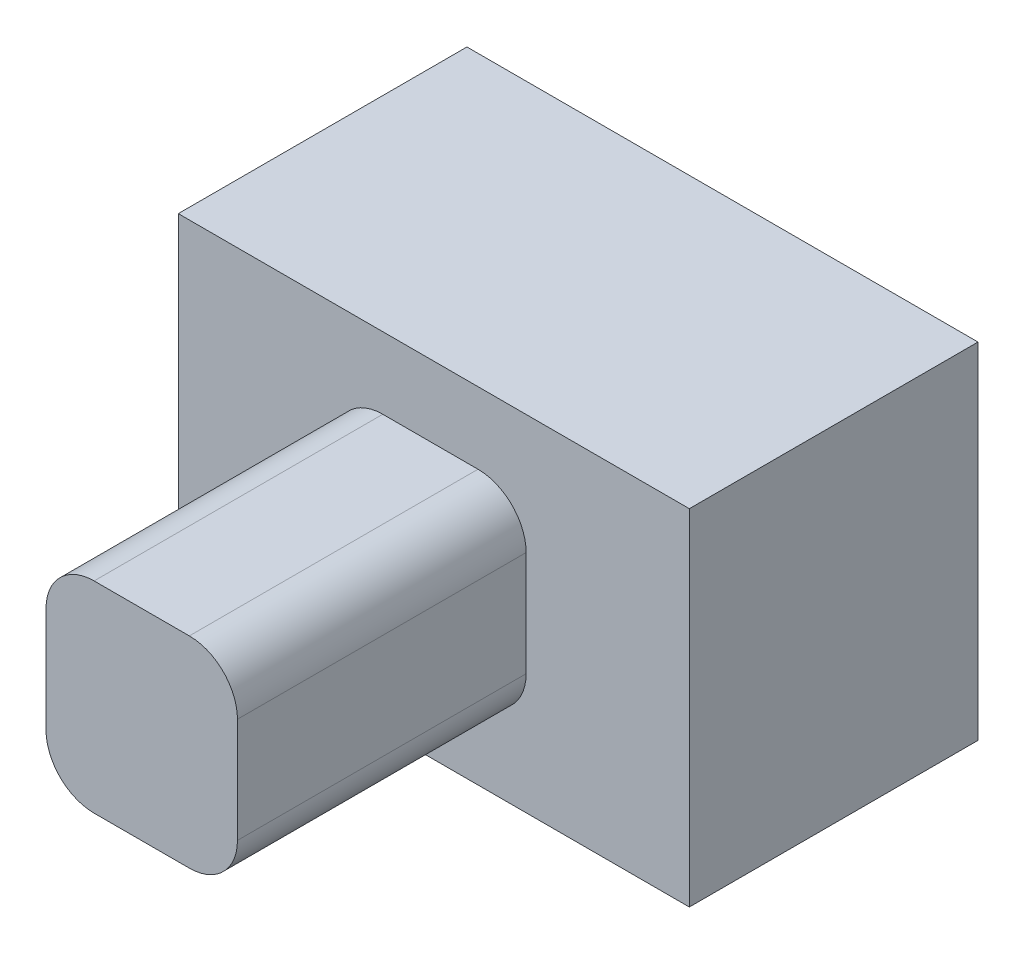
from build123d import *

# Parameters (mm, degrees)
SKETCH_1_W          = 10.622879294
SKETCH_1_H          = 7.171059062
EXTRUDE_1_DEPTH     = 6
EXTRUDE_2_DEPTH     = 6
SKETCH_3_W          = 1.75
SKETCH_3_H          = 1.75
CUT_EXTRUDE_1_DEPTH = 4


with BuildPart() as part:
    # 草图1 → 凸台-拉伸1 (new body)
    with BuildSketch(Plane.XY):
        with Locations((2.891532243, 0.829398912)):
            Rectangle(SKETCH_1_W, SKETCH_1_H)
    extrude(amount=EXTRUDE_1_DEPTH)

    # 草图2 → 凸台-拉伸2 (add)
    with BuildSketch(Plane.XY.offset(6)):
        with BuildLine():
            Line((1.830465057, 2.928210333), (3.810000549, 2.928210333))
            ThreePointArc((3.810000549, 2.928210333), (4.51710733, 2.635317114), (4.810000549, 1.928210333))
            Line((4.810000549, 1.928210333), (4.810000549, -0.252824237))
            ThreePointArc((4.810000549, -0.252824237), (4.51710733, -0.959931018), (3.810000549, -1.252824237))
            Line((3.810000549, -1.252824237), (1.830465057, -1.252824237))
            ThreePointArc((1.830465057, -1.252824237), (1.123358276, -0.959931018), (0.830465057, -0.252824237))
            Line((0.830465057, -0.252824237), (0.830465057, 1.928210333))
            ThreePointArc((0.830465057, 1.928210333), (1.123358276, 2.635317114), (1.830465057, 2.928210333))
        make_face()
    extrude(amount=EXTRUDE_2_DEPTH)

    # 草图3 → 切除-拉伸1 (cut)
    with BuildSketch(Plane(origin=(0, 0, 0), x_dir=(-1, 0, 0), z_dir=(0, 0, -1))):
        with Locations((-2.744430707, 0.686146252)):
            Rectangle(SKETCH_3_W, SKETCH_3_H)
    extrude(amount=-CUT_EXTRUDE_1_DEPTH, mode=Mode.SUBTRACT)


solid = part.part
